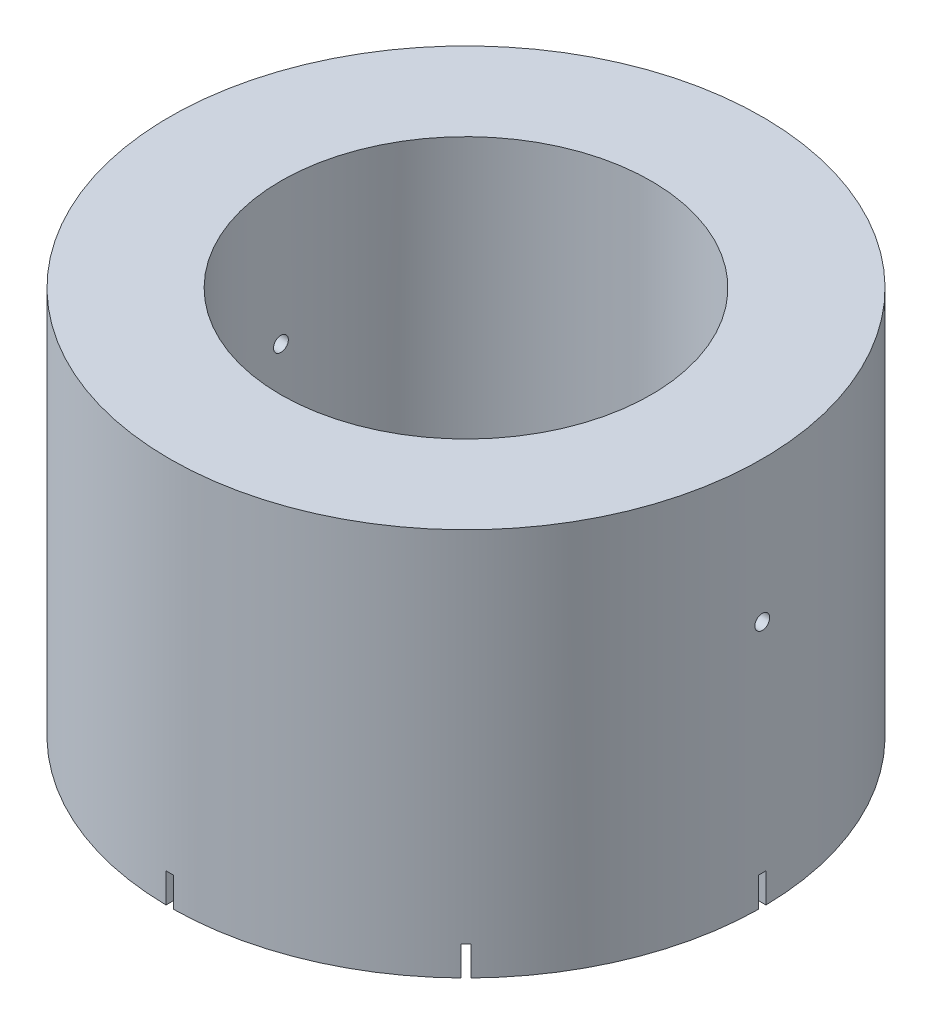
from build123d import *

# Parameters (mm, degrees)
SKETCH1_R               = 40
SKETCH1_R_2             = 25
BOSS_EXTRUDE1_DEPTH     = 50
SKETCH2_R               = 40
SKETCH2_R_2             = 37.5
BOSS_EXTRUDE2_DEPTH     = 5
SKETCH3_R               = 1
CUT_EXTRUDE2_DEPTH      = 41
CUT_EXTRUDE2_DEPTH_BACK = 41
SKETCH4_W               = 1
SKETCH4_H               = 6.6
CUT_EXTRUDE3_DEPTH      = 41.0000001
CIRPATTERN1_COUNT       = 4
CIRPATTERN1_ANGLE       = 135
SKETCH5_R               = 61.08994387
CUT_EXTRUDE4_DEPTH      = 2.6


with BuildPart() as part:
    # Sketch1 → Boss-Extrude1 (new body)
    with BuildSketch(Plane(origin=(0, 0, 0), x_dir=(1, 0, 0), z_dir=(0, 1, 0))):
        Circle(SKETCH1_R)
        Circle(SKETCH1_R_2, mode=Mode.SUBTRACT)
    extrude(amount=BOSS_EXTRUDE1_DEPTH)

    # Sketch2 → Boss-Extrude2 (add)
    with BuildSketch(Plane.XZ):
        Circle(SKETCH2_R)
        Circle(SKETCH2_R_2, mode=Mode.SUBTRACT)
    extrude(amount=BOSS_EXTRUDE2_DEPTH)

    # Sketch3 → Cut-Extrude2 (cut, two sides)
    with BuildSketch(Plane(origin=(0, 0, 0), x_dir=(0, 0, -1), z_dir=(1, 0, 0))) as cut_extrude2_sk:
        with Locations((0, 30.95)):
            Circle(SKETCH3_R)
    extrude(amount=CUT_EXTRUDE2_DEPTH, mode=Mode.SUBTRACT)
    extrude(cut_extrude2_sk.sketch, amount=-CUT_EXTRUDE2_DEPTH_BACK, mode=Mode.SUBTRACT)

    # Sketch4 → Cut-Extrude3 (cut, symmetric)
    with BuildSketch(Plane.XY):
        with Locations((0, -1.7)):
            Rectangle(SKETCH4_W, SKETCH4_H)
    cut_extrude3 = extrude(amount=CUT_EXTRUDE3_DEPTH, both=True, mode=Mode.SUBTRACT)

    # CirPattern1: Cut-Extrude3 ×4 about axis
    cirpattern1_axis = Axis((0, 0, 0), (0, 1, 0))
    for i in range(1, CIRPATTERN1_COUNT):
        add(cut_extrude3.rotate(cirpattern1_axis, i * CIRPATTERN1_ANGLE / (CIRPATTERN1_COUNT - 1)), mode=Mode.SUBTRACT)

    # Sketch5 → Cut-Extrude4 (cut)
    with BuildSketch(Plane.XZ.offset(5)):
        Circle(SKETCH5_R)
    extrude(amount=-CUT_EXTRUDE4_DEPTH, mode=Mode.SUBTRACT)


solid = part.part
